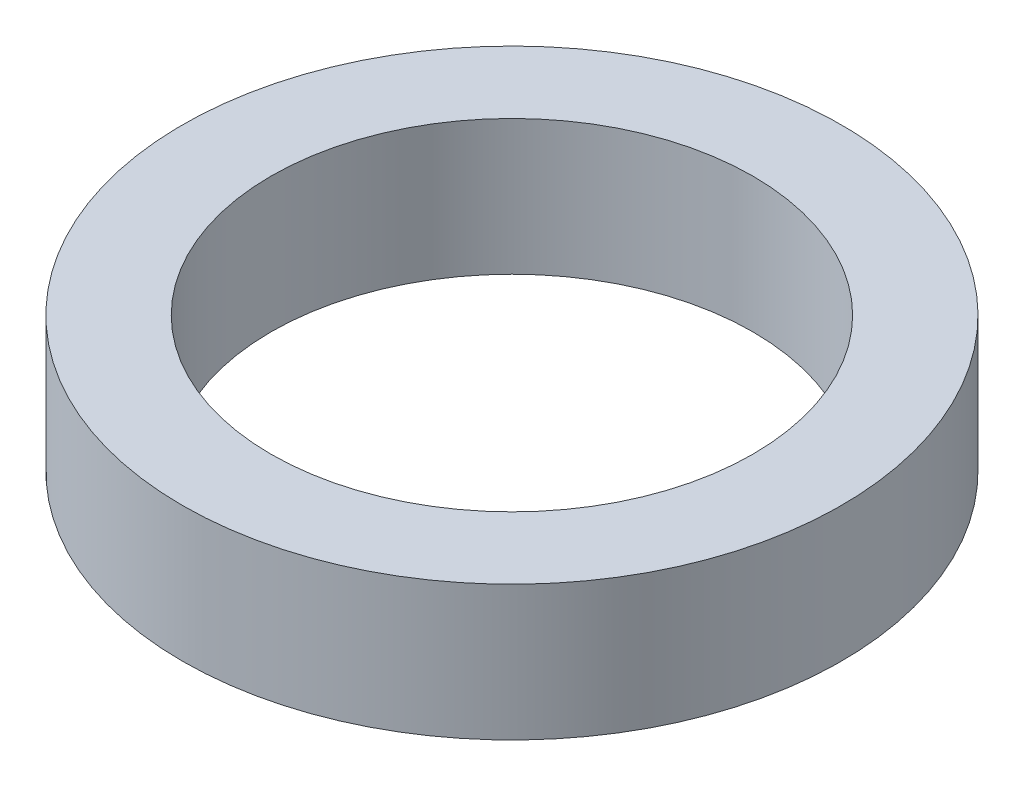
from build123d import *

# Parameters (mm, degrees)
SKETCH1_R           = 17.1
SKETCH1_R_2         = 12.5
BOSS_EXTRUDE1_DEPTH = 7


with BuildPart() as part:
    # Sketch1 → Boss-Extrude1 (new body)
    with BuildSketch(Plane(origin=(0, 0, 0), x_dir=(1, 0, 0), z_dir=(0, 1, 0))):
        Circle(SKETCH1_R)
        Circle(SKETCH1_R_2, mode=Mode.SUBTRACT)
    extrude(amount=BOSS_EXTRUDE1_DEPTH)


solid = part.part
